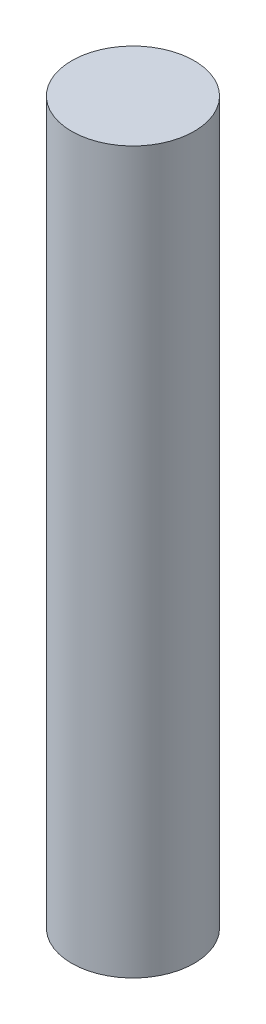
from build123d import *

# Parameters (mm, degrees)
SKETCH1_R           = 8.5
BOSS_EXTRUDE1_DEPTH = 100


with BuildPart() as part:
    # Sketch1 → Boss-Extrude1 (new body)
    with BuildSketch(Plane(origin=(0, 0, 0), x_dir=(1, 0, 0), z_dir=(0, 1, 0))):
        Circle(SKETCH1_R)
    extrude(amount=BOSS_EXTRUDE1_DEPTH)


solid = part.part
